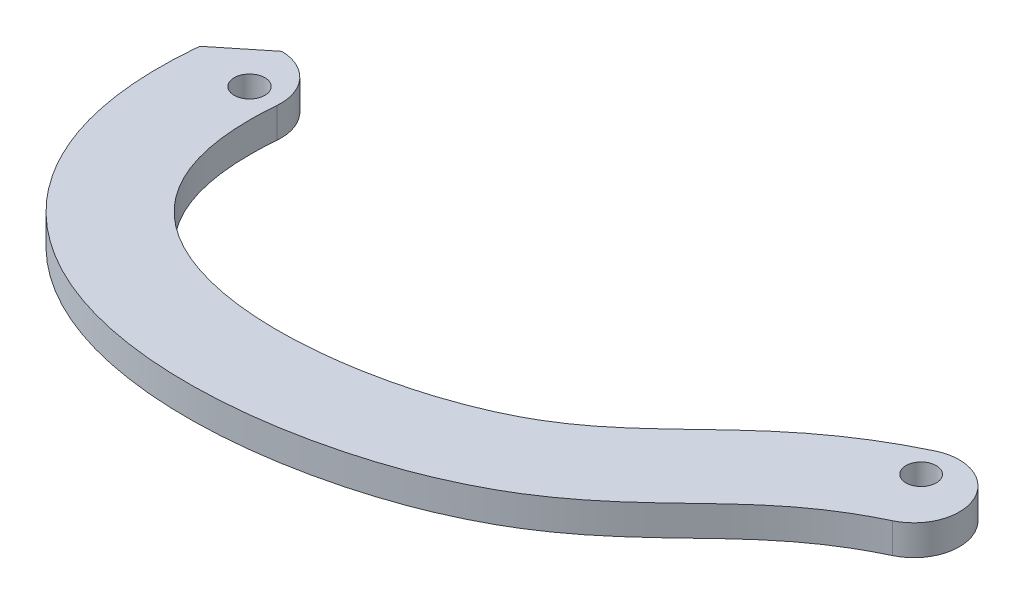
from build123d import *

# Parameters (mm, degrees)
SKETCH1_R           = 1.6129
SKETCH1_R_2         = 1.5875
BOSS_EXTRUDE1_DEPTH = 3.175
CUT_EXTRUDE1_REACH  = 5.175


with BuildPart() as part:
    # Sketch1 → Boss-Extrude1 (new body)
    with BuildSketch(Plane(origin=(0, 0, 0), x_dir=(1, 0, 0), z_dir=(0, 1, 0))):
        with BuildLine():
            ThreePointArc((-32.142793863, -0.273408004), (-36.477491062, 4.881513207), (-41.632412273, 0.546816008))
            add(Edge.make_bspline(
                [(38.035586667, -5.733398349), (37.638456287, -5.922466284), (36.836942575, -6.321273918), (35.371138332, -7.116261195), (33.693170464, -8.143185315), (31.883886812, -9.42020902), (29.648378201, -11.198676514), (27.036028795, -13.592789636), (22.679976617, -17.831524884), (17.211739573, -22.499159659), (9.396423134, -26.315794857), (0.576595974, -29.205533013), (-9.337135311, -30.642162686), (-19.330270602, -29.840555436), (-26.618230144, -27.80035627), (-32.213942131, -24.514308128), (-36.014693252, -20.74489615), (-38.392774611, -17.364575843), (-40.192531501, -13.487083667), (-41.355396656, -9.192066449), (-41.782608077, -5.300476187), (-41.804321571, -2.028547037), (-41.705805772, -0.302313361), (-41.632412273, 0.546816008)],
                knots=[0, 0, 0, 0, 0.015625, 0.03125, 0.0625, 0.09375, 0.125, 0.1875, 0.25, 0.375, 0.4375, 0.5, 0.625, 0.6875, 0.75, 0.8125, 0.84375, 0.875, 0.90625, 0.9375, 0.96875, 0.984375, 1, 1, 1, 1], degree=3))
            ThreePointArc((38.035586667, -5.733398349), (40.288445428, 0.613840413), (33.941206667, 2.866699175))
            add(Edge.make_bspline(
                [(33.941206667, 2.866699175), (33.444862745, 2.63039713), (32.446678251, 2.133753144), (30.593455222, 1.129003811), (28.454502342, -0.17993207), (26.158764415, -1.801029891), (23.397639254, -4.000211026), (20.408833118, -6.751200435), (17.199476649, -9.871715537), (13.993340911, -12.700434126), (10.991950499, -14.796301145), (8.166682163, -16.313492063), (4.956712956, -17.733599771), (0.363730133, -19.250343795), (-5.672765293, -20.456505214), (-11.837126413, -20.883216065), (-17.729783319, -20.392870826), (-22.95250941, -18.893094147), (-26.462588517, -16.790688539), (-28.698373992, -14.567923675), (-30.090943107, -12.59116295), (-31.186712287, -10.245348167), (-31.822530926, -7.925351865), (-32.135142613, -5.82120044), (-32.263078141, -4.114852993), (-32.273485933, -2.578959429), (-32.220503872, -1.288018796), (-32.171746437, -0.608376098), (-32.142793863, -0.273408004)],
                knots=[0, 0, 0, 0, 0.015625, 0.03125, 0.0625, 0.09375, 0.125, 0.1875, 0.25, 0.3125, 0.375, 0.40625, 0.4375, 0.5, 0.5625, 0.625, 0.6875, 0.75, 0.8125, 0.84375, 0.875, 0.90625, 0.9375, 0.953125, 0.96875, 0.984375, 0.9921875, 1, 1, 1, 1], degree=3))
        make_face()
        with Locations((-35.306, 0)):
            Circle(SKETCH1_R, mode=Mode.SUBTRACT)
        with Locations((35.306, 0)):
            Circle(SKETCH1_R_2, mode=Mode.SUBTRACT)
    extrude(amount=BOSS_EXTRUDE1_DEPTH)

    # Sketch3 → Cut-Extrude1 (cut, up to next)
    with BuildSketch(Plane(origin=(0, 3.175, 0), x_dir=(1, 0, 0), z_dir=(0, 1, 0)), mode=Mode.PRIVATE) as cut_extrude1_sk1:
        with BuildLine():
            Line((-41.556602668, 1.07577215), (-36.819106421, 4.8987114))
            ThreePointArc((-36.819106421, 4.8987114), (-39.878401119, 3.842986947), (-41.556602668, 1.07577215))
        make_face()
    cut_extrude1_tool1 = extrude(cut_extrude1_sk1.sketch, amount=-CUT_EXTRUDE1_REACH, mode=Mode.PRIVATE) & part.part
    add(cut_extrude1_tool1.solids().sort_by_distance((-39.467003, 3.175, -3.33317))[0], mode=Mode.SUBTRACT)


solid = part.part
